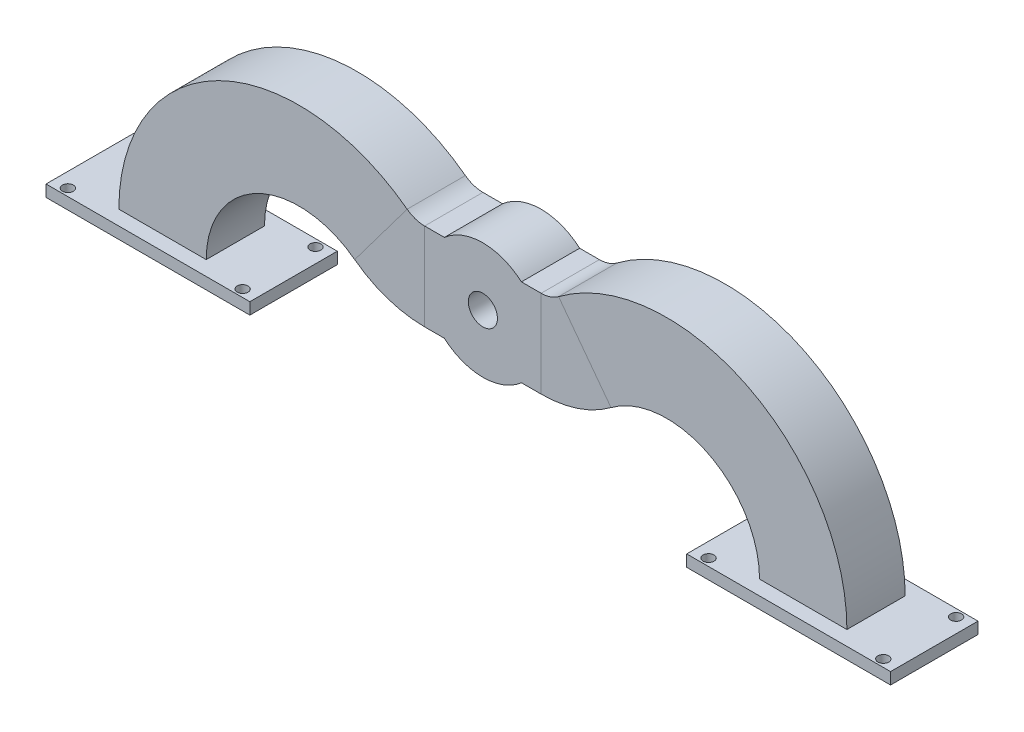
from build123d import *

# Parameters (mm, degrees)
SKETCH1_R               = 20
SKETCH1_R_2             = 5
BOSS_EXTRUDE1_DEPTH     = 20
SKETCH3_W               = 20
SKETCH3_H               = 30
SKETCH3_W_2             = 15
SKETCH3_H_2             = 20
SKETCH4_R               = 5
CUT_EXTRUDE1_DEPTH      = 1
CUT_EXTRUDE1_DEPTH_BACK = 21
SKETCH5_R               = 10
CUT_EXTRUDE2_DEPTH      = 1
CUT_EXTRUDE2_DEPTH_BACK = 17.5
SKETCH6_W               = 70
SKETCH6_H               = 30.026464272
SKETCH6_R               = 1.868076344
SKETCH6_W_2             = 20
SKETCH6_H_2             = 15
BOSS_EXTRUDE2_DEPTH     = 4


with BuildPart() as part:
    # Sketch1 → Boss-Extrude1 (new body)
    with BuildSketch(Plane.XY):
        Circle(SKETCH1_R)
        Circle(SKETCH1_R_2, mode=Mode.SUBTRACT)
    extrude(amount=BOSS_EXTRUDE1_DEPTH)

    # Sweep1: sweep along a path in Sketch2
    with BuildLine(Plane.XY) as sweep1_path:
        Line((0, 0), (-20, 0))
        ThreePointArc((-20, 0), (-27.90569415, 1.282917549), (-35, 5))
        ThreePointArc((-35, 5), (-84.088137289, 9.426274578), (-110, -32.5))
    # Sketch3 → Sweep1 (sweep)
    with BuildSketch(Plane(origin=(0, 0, 0), x_dir=(0, 0, -1), z_dir=(1, 0, 0))):
        with Locations((-10, 0)):
            Rectangle(SKETCH3_W, SKETCH3_H)
        with Locations((-10, 0)):
            Rectangle(SKETCH3_W_2, SKETCH3_H_2, mode=Mode.SUBTRACT)
    sweep(path=sweep1_path.line)

    # Mirror1: part across plane


with BuildPart() as part_1:
    add(part.part)
    add(part.part.mirror(Plane(origin=(0, 0, 0), x_dir=(0, 0, 1), z_dir=(1, 0, 0))))

    # Sketch4 → Cut-Extrude1 (cut, two sides)
    with BuildSketch(Plane.XY.offset(20)) as cut_extrude1_sk:
        Circle(SKETCH4_R)
    extrude(amount=CUT_EXTRUDE1_DEPTH, mode=Mode.SUBTRACT)
    extrude(cut_extrude1_sk.sketch, amount=-CUT_EXTRUDE1_DEPTH_BACK, mode=Mode.SUBTRACT)

    # Sketch5 → Cut-Extrude2 (cut, two sides)
    with BuildSketch(Plane(origin=(0, 0, 0), x_dir=(-1, 0, 0), z_dir=(0, 0, -1))) as cut_extrude2_sk:
        with Locations((-25, 0)):
            Circle(SKETCH5_R)
        with Locations((25, 0)):
            Circle(SKETCH5_R)
    extrude(amount=CUT_EXTRUDE2_DEPTH, mode=Mode.SUBTRACT)
    extrude(cut_extrude2_sk.sketch, amount=-CUT_EXTRUDE2_DEPTH_BACK, mode=Mode.SUBTRACT)

    # Sketch6 → Boss-Extrude2 (add)
    with BuildSketch(Plane.XZ.offset(32.5)):
        with Locations((110, 10)):
            Rectangle(SKETCH6_W, SKETCH6_H)
        with Locations((80, 22.5)):
            Circle(SKETCH6_R, mode=Mode.SUBTRACT)
        with Locations((140, 22.5)):
            Circle(SKETCH6_R, mode=Mode.SUBTRACT)
        with Locations((140, -2.5)):
            Circle(SKETCH6_R, mode=Mode.SUBTRACT)
        with Locations((80, -2.5)):
            Circle(SKETCH6_R, mode=Mode.SUBTRACT)
        with Locations((110, 10)):
            Rectangle(SKETCH6_W_2, SKETCH6_H_2, mode=Mode.SUBTRACT)
    extrude(amount=BOSS_EXTRUDE2_DEPTH)

    # Mirror2: part across plane


with BuildPart() as part_2:
    add(part_1.part)
    add(part_1.part.mirror(Plane(origin=(0, 0, 0), x_dir=(0, 0, 1), z_dir=(1, 0, 0))))


solid = part_2.part
